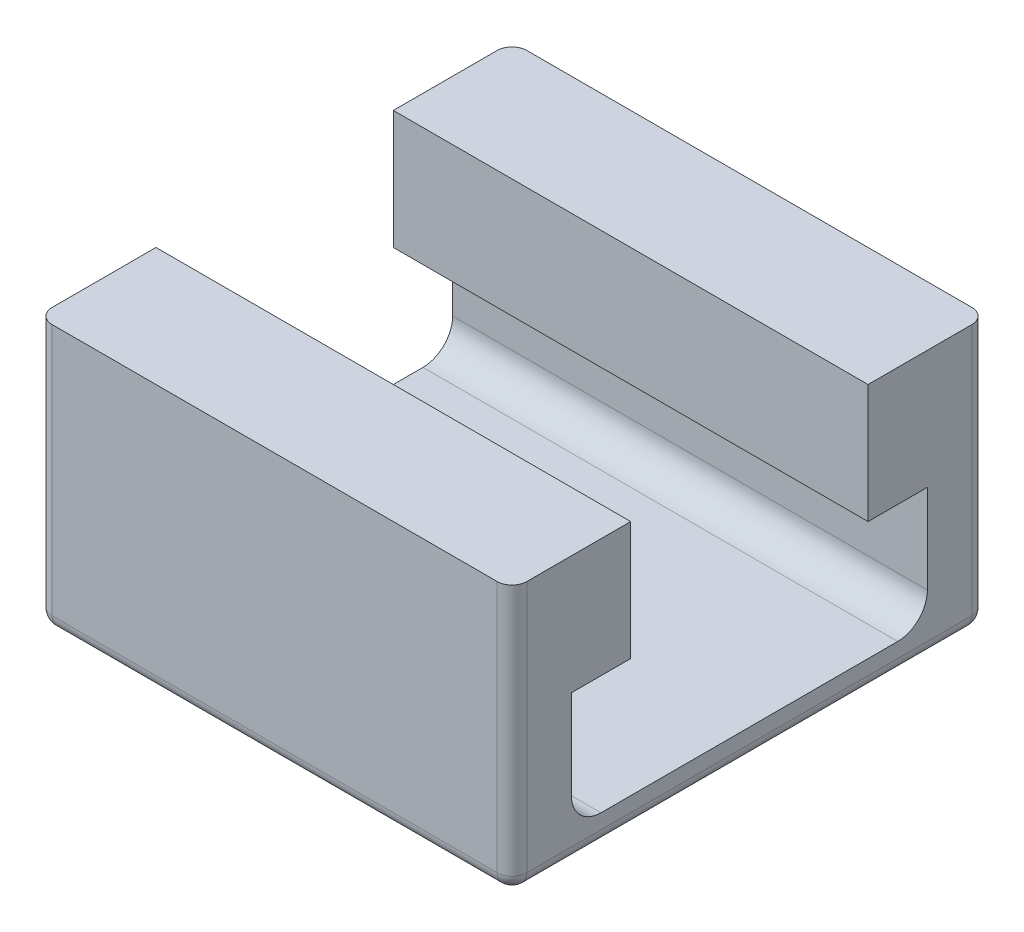
from build123d import *

# Parameters (mm, degrees)
EXTRUDE_1_DEPTH = 8
FILLET_1_R      = 0.25


with BuildPart() as part:
    # 草圖1 → 填料-伸長1 (new body)
    with BuildSketch(Plane(origin=(0, 0, 0), x_dir=(0, 0, -1), z_dir=(1, 0, 0))):
        with BuildLine():
            Line((0, 0), (0, 4.5))
            Line((0, 4.5), (2, 4.5))
            Line((2, 4.5), (2, 2.5))
            Line((2, 2.5), (1, 2.5))
            Line((1, 2.5), (1, 1))
            ThreePointArc((1, 1), (1.146446609, 0.646446609), (1.5, 0.5))
            Line((1.5, 0.5), (6.5, 0.5))
            ThreePointArc((6.5, 0.5), (6.853553391, 0.646446609), (7, 1))
            Line((7, 1), (7, 2.5))
            Line((7, 2.5), (6, 2.5))
            Line((6, 2.5), (6, 4.5))
            Line((6, 4.5), (8, 4.5))
            Line((8, 4.5), (8, 0))
            Line((8, 0), (0, 0))
        make_face()
    extrude(amount=-EXTRUDE_1_DEPTH)

    # 圓角1
    fillet_1_edges = [part.edges().sort_by_distance(p)[0] for p in [
        (0, 2.25, 0),
        (0, 2.25, -8),
        (0, 0, -4),
        (-4, 0, 0),
        (-4, 0, -8),
        (-8, 0, -4),
        (-8, 2.25, 0),
        (-8, 2.25, -8),
    ]]
    fillet(fillet_1_edges, radius=FILLET_1_R)


solid = part.part
